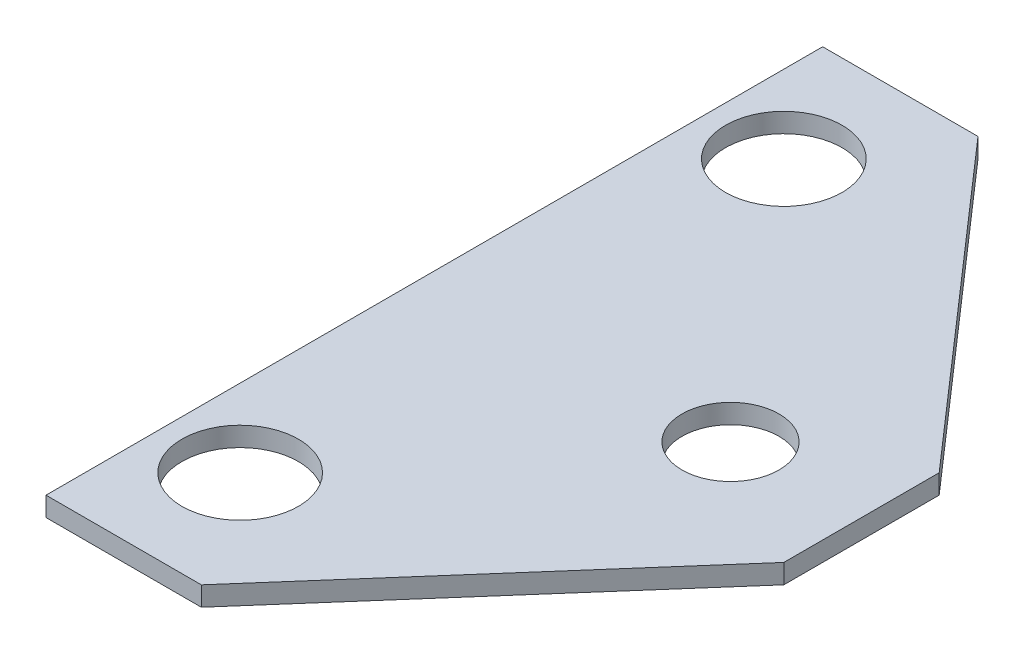
from build123d import *

# Parameters (mm, degrees)
BOSS_EXTRUDE1_DEPTH       = 0.5
F_3_0MM_DOWEL_HOLE1_D     = 3
F_3_0MM_DOWEL_HOLE1_DEPTH = 12.75
F_3_0MM_DOWEL_HOLE1_TIP   = 0.901290929
M3_TAPPED_HOLE2_D         = 2.5
M3_TAPPED_HOLE2_DEPTH     = 7.5
M3_TAPPED_HOLE2_TIP       = 0.751075774


with BuildPart() as part:
    # Sketch1 → Boss-Extrude1 (new body)
    with BuildSketch(Plane(origin=(0, 0, 0), x_dir=(1, 0, 0), z_dir=(0, 1, 0))):
        Polygon((-0.59160691, 16.53307367), (-0.59160691, -3.46692633), (3.40839309, -3.46692633), (10.40839309, 4.53307367), (10.40839309, 6.53307367), (10.40839309, 8.53307367), (3.40839309, 16.53307367), align=None)
    extrude(amount=BOSS_EXTRUDE1_DEPTH)

    # Ø3.0mm Dowel Hole1
    with Locations(Plane(origin=(1.40839309, 0.5, -13.53307367), x_dir=(0, 0, 1), z_dir=(0, 1, 0))):
        with Locations((0, 0), (14, 0)):
            Hole(F_3_0MM_DOWEL_HOLE1_D / 2, depth=F_3_0MM_DOWEL_HOLE1_DEPTH)
            with Locations((0, 0, -(F_3_0MM_DOWEL_HOLE1_DEPTH + F_3_0MM_DOWEL_HOLE1_TIP / 2))):  # 118° drill point
                Cone(0, F_3_0MM_DOWEL_HOLE1_D / 2, F_3_0MM_DOWEL_HOLE1_TIP, mode=Mode.SUBTRACT)

    # M3 Tapped Hole2
    with Locations(Plane(origin=(7.034946216, 0, -6.53307367), x_dir=(0, 0, -1), z_dir=(0, -1, 0))):
        with Locations((0, 0)):
            Hole(M3_TAPPED_HOLE2_D / 2, depth=M3_TAPPED_HOLE2_DEPTH)
            with Locations((0, 0, -(M3_TAPPED_HOLE2_DEPTH + M3_TAPPED_HOLE2_TIP / 2))):  # 118° drill point
                Cone(0, M3_TAPPED_HOLE2_D / 2, M3_TAPPED_HOLE2_TIP, mode=Mode.SUBTRACT)


solid = part.part
